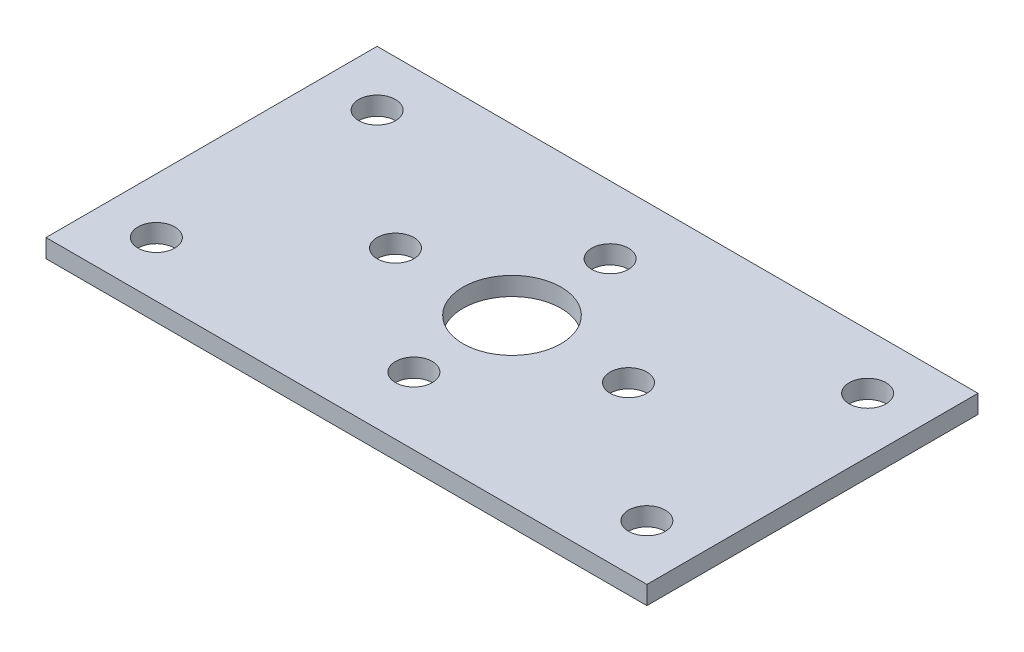
from build123d import *

# Parameters (mm, degrees)
SKETCH1_W               = 49
SKETCH1_H               = 27
BOSS_EXTRUDE1_DEPTH     = 1.5
CUT_EXTRUDE1_DEPTH      = 10
CUT_EXTRUDE1_DEPTH_BACK = 10
SKETCH2_R               = 1.5
CUT_EXTRUDE2_DEPTH      = 10
CUT_EXTRUDE2_DEPTH_BACK = 10
SKETCH3_R               = 1.5
SKETCH3_R_2             = 4


with BuildPart() as part:
    # Sketch1 → Boss-Extrude1 (new body)
    with BuildSketch(Plane(origin=(0, 0, 0), x_dir=(1, 0, 0), z_dir=(0, 1, 0))):
        with Locations((24.5, 13.5)):
            Rectangle(SKETCH1_W, SKETCH1_H)
    extrude(amount=BOSS_EXTRUDE1_DEPTH)

    # Sketch2 → Cut-Extrude1 (cut, two sides: drawn at the far end of the back side and taken through both)
    with BuildSketch(Plane(origin=(0, 1.5, 0), x_dir=(1, 0, 0), z_dir=(0, 1, 0)).offset(-CUT_EXTRUDE1_DEPTH_BACK)):
        with Locations((4.5, 22.5)):
            Circle(SKETCH2_R)
        with Locations((4.5, 4.5)):
            Circle(SKETCH2_R)
        with Locations((44.5, 4.5)):
            Circle(SKETCH2_R)
        with Locations((44.5, 22.5)):
            Circle(SKETCH2_R)
    extrude(amount=CUT_EXTRUDE1_DEPTH + CUT_EXTRUDE1_DEPTH_BACK, mode=Mode.SUBTRACT)

    # Sketch3 → Cut-Extrude2 (cut, two sides: drawn at the far end of the back side and taken through both)
    with BuildSketch(Plane(origin=(0, 1.5, 0), x_dir=(1, 0, 0), z_dir=(0, 1, 0)).offset(-CUT_EXTRUDE2_DEPTH_BACK)):
        with Locations((15, 13.5)):
            Circle(SKETCH3_R)
        with Locations((34, 13.5)):
            Circle(SKETCH3_R)
        with Locations((24.5, 21.5)):
            Circle(SKETCH3_R)
        with Locations((24.5, 5.5)):
            Circle(SKETCH3_R)
        with Locations((24.5, 13.5)):
            Circle(SKETCH3_R_2)
    extrude(amount=CUT_EXTRUDE2_DEPTH + CUT_EXTRUDE2_DEPTH_BACK, mode=Mode.SUBTRACT)


solid = part.part
